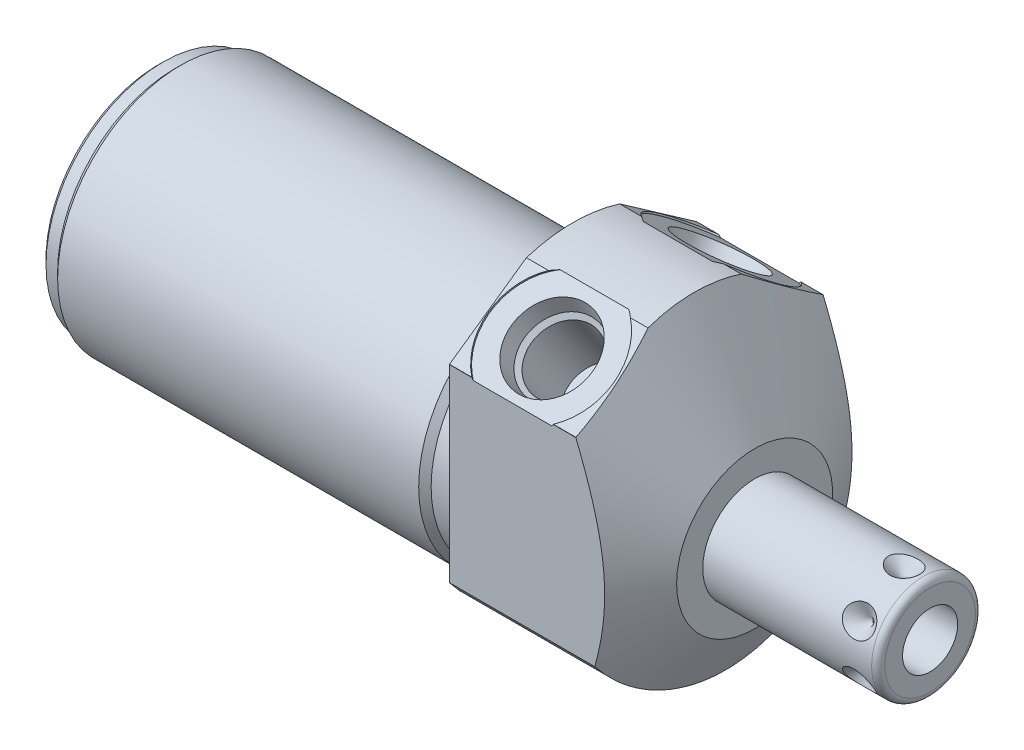
from build123d import *

# Parameters (mm, degrees)
SKETCH1_R           = 23.8125
EXTRUDE1_DEPTH      = 27.7876
EXTRUDE1_DEPTH_BACK = 63.5
CUT_EXTRUDE1_REACH  = 65.5
SKETCH2_R           = 23.8125
SKETCH2_R_2         = 18.8595
CUT_EXTRUDE3_START  = -27.7876
SKETCH4_R           = 28.575
CUT_EXTRUDE3_DEPTH  = 27.7876
SKETCH18_R          = 9.525
CUT_EXTRUDE4_DEPTH  = 0.254
SKETCH19_R          = 9.525
CUT_EXTRUDE5_DEPTH  = 0.254
CHAMFER1_SIZE       = 0.762
CIRPATTERN1_COUNT   = 6


with BuildPart() as part:
    # Sketch1 → Extrude1 (new body, two sides)
    with BuildSketch(Plane(origin=(0, 0, 0), x_dir=(0, 0, -1), z_dir=(1, 0, 0))) as extrude1_sk:
        Circle(SKETCH1_R)
    extrude(amount=EXTRUDE1_DEPTH)
    extrude(extrude1_sk.sketch, amount=-EXTRUDE1_DEPTH_BACK)

    # Sketch2 → Cut-Extrude1 (cut, up to next)
    with BuildSketch(Plane(origin=(0, 0, 0), x_dir=(0, 0, -1), z_dir=(1, 0, 0)), mode=Mode.PRIVATE) as cut_extrude1_sk1:
        Circle(SKETCH2_R)
        with Locations((0, -4.191)):
            Circle(SKETCH2_R_2, mode=Mode.SUBTRACT)
    cut_extrude1_tool1 = extrude(cut_extrude1_sk1.sketch, amount=-CUT_EXTRUDE1_REACH, mode=Mode.PRIVATE) & part.part
    add(cut_extrude1_tool1.solids().sort_by_distance((0, 0, 23.138981))[0], mode=Mode.SUBTRACT)

    # Sketch4 → Cut-Extrude3 (cut)
    with BuildSketch(Plane.ZY.offset(CUT_EXTRUDE3_START)):
        Circle(SKETCH4_R)
        with BuildLine():
            Line((18.923, -14.455283714), (18.923, 14.465869871))
            Line((18.923, 14.465869871), (0, 27.715897117))
            Line((0, 27.715897117), (-18.923, 14.465869871))
            Line((-18.923, 14.465869871), (-18.923, -14.455283714))
            ThreePointArc((-18.923, -14.455283714), (0, -23.8125), (18.923, -14.455283714))
        make_face(mode=Mode.SUBTRACT)
    extrude(amount=CUT_EXTRUDE3_DEPTH, mode=Mode.SUBTRACT)

    # Sketch6 → Cut-Revolve2 (revolve, cut)
    with BuildSketch(Plane.XY, mode=Mode.PRIVATE) as cut_revolve2_sk:
        Polygon((4.764025965, 47.625), (27.7876, 7.747), (27.7876, 47.625), align=None)
    revolve(cut_revolve2_sk.sketch.rotate(Axis((3.612847264, -4.191, 0), (1, 0, 0)), 270), axis=Axis((3.612847264, -4.191, 0), (1, 0, 0)), mode=Mode.SUBTRACT)  # turned: the seam where the file's is

    # S2D0002 → Cut-Revolve3 (revolve, cut)
    with BuildSketch(Plane(origin=(9.652, 18.394824642, 12.869035589), x_dir=(0, 0.573576436, -0.819152044), z_dir=(1, 0, 0))):
        Polygon((0, 0), (6.1849, 0), (5.642306865, -2.5527), (4.9784, -3.216606865), (4.9784, -13.462), (0, -13.462), align=None)
    revolve(axis=Axis((9.652, 6.816028581, 4.761475303), (0, 0.819152044, 0.573576436)), mode=Mode.SUBTRACT)

    # Sketch8 → Cut-Revolve4 (revolve, cut)
    with BuildSketch(Plane(origin=(9.652, 18.394824642, -12.869035589), x_dir=(0, -0.573576436, -0.819152044), z_dir=(1, 0, 0))):
        Polygon((0, 0), (6.1849, 0), (5.642306865, -2.5527), (4.9784, -3.216606865), (4.9784, -13.462), (0, -13.462), align=None)
    revolve(axis=Axis((9.652, 6.816028581, -4.761475303), (0, 0.819152044, -0.573576436)), mode=Mode.SUBTRACT)

    # Sketch18 → Cut-Extrude4 (cut)
    with BuildSketch(Plane(origin=(0, 18.59764611, 13.022211999), x_dir=(1, 0, 0), z_dir=(0, 0.819152044, 0.573576436))):
        with Locations((9.652, 0.009141155)):
            Circle(SKETCH18_R)
    extrude(amount=-CUT_EXTRUDE4_DEPTH, mode=Mode.SUBTRACT)

    # Sketch19 → Cut-Extrude5 (cut)
    with BuildSketch(Plane(origin=(0, 18.59764611, -13.022211999), x_dir=(1, 0, 0), z_dir=(0, 0.819152044, -0.573576436))):
        with Locations((9.652, -0.009141155)):
            Circle(SKETCH19_R)
    extrude(amount=-CUT_EXTRUDE5_DEPTH, mode=Mode.SUBTRACT)

    # Sketch10 → Cut-Revolve6 (revolve, cut)
    with BuildSketch(Plane.XY, mode=Mode.PRIVATE) as cut_revolve6_sk:
        Polygon((0, 14.6685), (0, 13.716), (-3.81, 13.716), (-4.7625, 14.6685), align=None)
    revolve(cut_revolve6_sk.sketch.rotate(Axis((-5.000625, -4.191, 0), (1, 0, 0)), 90), axis=Axis((-5.000625, -4.191, 0), (1, 0, 0)), mode=Mode.SUBTRACT)  # turned: the seam where the file's is

    # Sketch12 → Cut-Revolve8 (revolve, cut)
    with BuildSketch(Plane.XY, mode=Mode.PRIVATE) as cut_revolve8_sk:
        Polygon((-63.5, 14.6685), (-63.5, 13.716), (-60.96, 13.716), (-60.0075, 14.6685), align=None)
    revolve(cut_revolve8_sk.sketch.rotate(Axis((-63.674625, -4.191, 0), (1, 0, 0)), 90), axis=Axis((-63.674625, -4.191, 0), (1, 0, 0)), mode=Mode.SUBTRACT)  # turned: the seam where the file's is

    # Chamfer1
    chamfer1_edges = [part.edges().sort_by_distance(p)[0] for p in [
        (-63.5, -4.191, -17.907),
    ]]
    chamfer(chamfer1_edges, length=CHAMFER1_SIZE)

    # Sketch13 → Revolve1 (revolve)
    with BuildSketch(Plane(origin=(0, 0, 0), x_dir=(0, -1, 0), z_dir=(0, 0, 1)), mode=Mode.PRIVATE) as revolve1_sk:
        with BuildLine():
            Line((4.191, 27.7876), (4.191, 54.6354))
            Line((4.191, 54.6354), (11.1125, 54.6354))
            ThreePointArc((11.1125, 54.6354), (11.83092049, 54.33782049), (12.1285, 53.6194))
            Line((12.1285, 53.6194), (12.1285, 27.7876))
            Line((12.1285, 27.7876), (4.191, 27.7876))
        make_face()
    revolve(revolve1_sk.sketch.rotate(Axis((26.44521, -4.191, 0), (1, 0, 0)), 270), axis=Axis((26.44521, -4.191, 0), (1, 0, 0)))  # turned: the seam where the file's is

    # S2D0001 → Cut-Revolve9 (revolve, cut)
    with BuildSketch(Plane(origin=(54.6354, -8.4074, 0), x_dir=(0, -1, 0), z_dir=(0, 0, 1)), mode=Mode.PRIVATE) as cut_revolve9_sk:
        Polygon((0, 0), (0, -15.24), (-4.2164, -17.773468714), (-4.2164, 0), align=None)
    revolve(cut_revolve9_sk.sketch.rotate(Axis((35.97325785, -4.191, 0), (1, 0, 0)), 270), axis=Axis((35.97325785, -4.191, 0), (1, 0, 0)), mode=Mode.SUBTRACT)  # turned: the seam where the file's is

    # Sketch16 → Cut-Revolve10 (revolve, cut)
    with BuildSketch(Plane(origin=(50.673, 3.7465, 0), x_dir=(-1, 0, 0), z_dir=(0, 0, -1)), mode=Mode.PRIVATE) as cut_revolve10_sk:
        Polygon((0, 0), (2.413, 0), (0, -2.413), align=None)
    cut_revolve10 = revolve(cut_revolve10_sk.sketch.rotate(Axis((50.673, -1.324519499, 0), (0, 1, 0)), 90), axis=Axis((50.673, -1.324519499, 0), (0, 1, 0)), mode=Mode.SUBTRACT)  # turned: the seam where the file's is

    # CirPattern1: Cut-Revolve10 ×6 about axis
    cirpattern1_axis = Axis((26.44521, -4.191, 0), (-1, 0, 0))
    for i in range(1, CIRPATTERN1_COUNT):
        add(cut_revolve10.rotate(cirpattern1_axis, i * 360 / CIRPATTERN1_COUNT), mode=Mode.SUBTRACT)


solid = part.part
